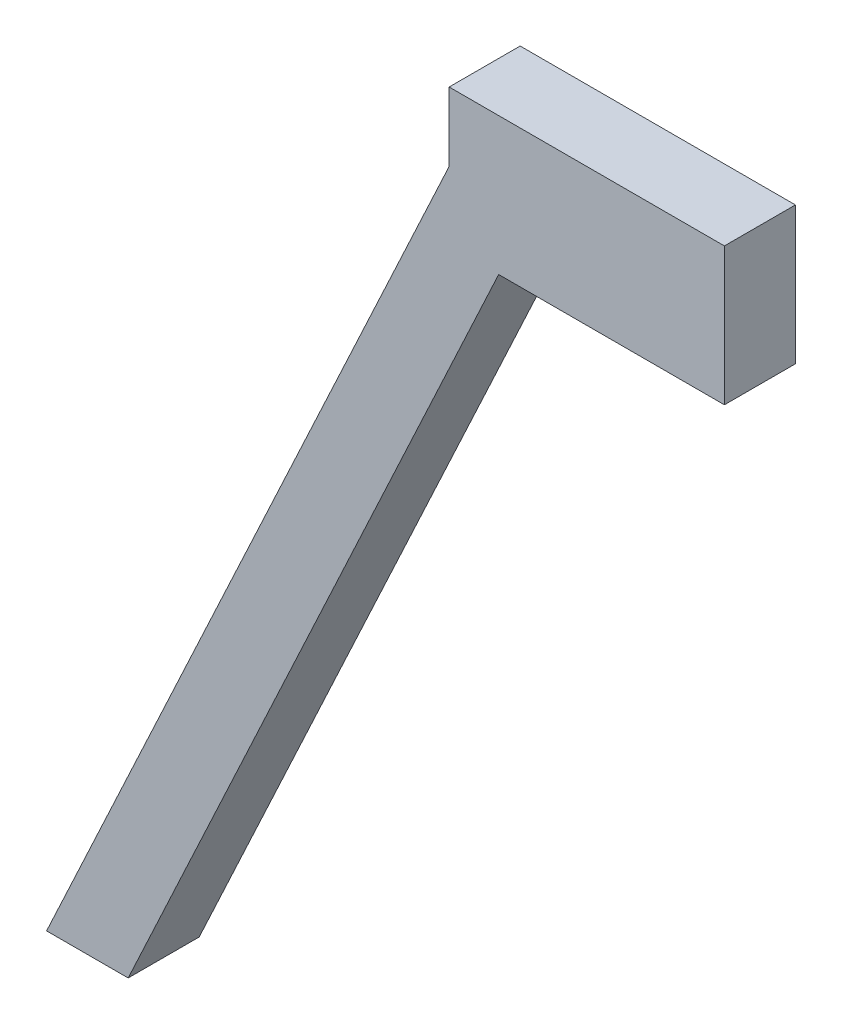
from build123d import *

# Parameters (mm, degrees)
BOSS_EXTRUDE1_DEPTH      = 10
BOSS_EXTRUDE1_DEPTH_BACK = 0.318278283
SKETCH3_R                = 3
CUT_EXTRUDE1_DEPTH       = 5
CUT_EXTRUDE2_DEPTH       = 15


with BuildPart() as part:
    # Sketch2 → Boss-Extrude1 (new body, two sides)
    with BuildSketch(Plane.XY) as boss_extrude1_sk:
        Polygon((14.539831303, 82.09905821), (-41.416945568, -37.900637039), (-51.156779582, -33.358877849), (7.345216778, 92.09905821), (7.345216778, 102.09905821), (47.345216778, 102.09905821), (47.345216778, 82.09905821), align=None)
    extrude(amount=BOSS_EXTRUDE1_DEPTH)
    extrude(boss_extrude1_sk.sketch, amount=-BOSS_EXTRUDE1_DEPTH_BACK)

    # Sketch3 → Cut-Extrude1 (cut)
    with BuildSketch(Plane.XZ.offset(-82.09905821)):
        with Locations((37.223217292, 5)):
            Circle(SKETCH3_R)
    extrude(amount=-CUT_EXTRUDE1_DEPTH, mode=Mode.SUBTRACT)

    # Sketch4 → Cut-Extrude2 (cut)
    with BuildSketch(Plane(origin=(0, 0, -0.318278283), x_dir=(-1, 0, 0), z_dir=(0, 0, -1))):
        Polygon((51.156779582, -33.358877849), (39.299088476, -33.358877849), (41.416945568, -37.900637039), align=None)
    extrude(amount=-CUT_EXTRUDE2_DEPTH, mode=Mode.SUBTRACT)


solid = part.part
